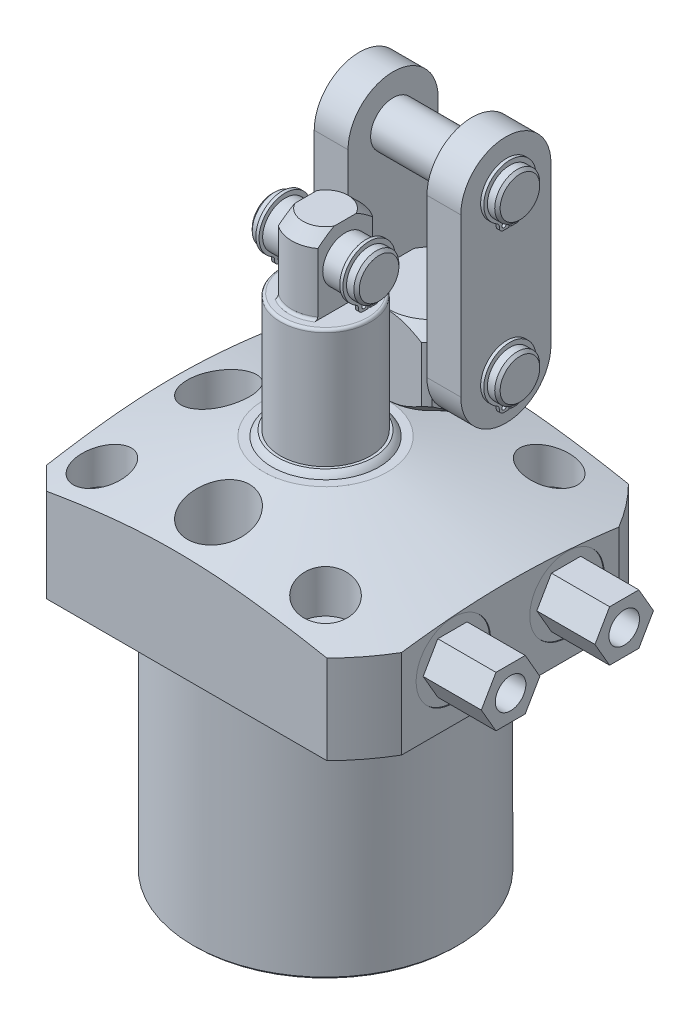
from build123d import *

# Parameters (mm, degrees)
SKETCH3_OUTSIDE_W          = 162.862
SKETCH3_OUTSIDE_H          = 162.862
SKETCH3_OUTSIDE_W_2        = 94.4626
SKETCH3_OUTSIDE_H_2        = 84.9376
CUT_EXTRUDE9_DEPTH         = 106.3498
CHAMFER8_SIZE              = 6.35
CHAMFER5_SIZE              = 0.762
HOLE1_D                    = 8.7376
HOLE1_DEPTH                = 36.4998
HOLE1_CBORE_D              = 14.2748
HOLE1_CBORE_DEPTH          = 17.4498
SKETCH34_R                 = 8.7503
CUT_EXTRUDE10_DEPTH        = 19.05
EXTRUDE14_DEPTH            = 16.383
HOLE2_D                    = 8.6106
HOLE2_DEPTH                = 6.7056
SKETCH33_R                 = 0.889
CUT_EXTRUDE7_DEPTH         = 20.6248
FILLET4_R                  = 0.762
SKETCH29_R                 = 6.3373
EXTRUDE11_DEPTH            = 15.0749
EXTRUDE2_START             = -2.8194
SKETCH16_R                 = 0.5969
EXTRUDE2_DEPTH             = 0.889
CHAMFER6_SIZE              = 0.762
CUT_EXTRUDE11_DEPTH        = 22.225
SKETCH30_R                 = 6.3373
EXTRUDE12_DEPTH            = 24.5999
EXTRUDE4_START             = -2.8194
SKETCH19_R                 = 0.5969
EXTRUDE4_DEPTH             = 0.889
EXTRUDE13_DEPTH            = 9.525
CHAMFER7_SIZE              = 0.762
LPATTERN2_COUNT            = 2
LPATTERN2_PITCH            = 44.45
LPATTERN2_START            = -2.8194
LPATTERN2_COPY_1_SKETCH_R  = 0.5969
LPATTERN2_COPY_1_DEPTH     = 0.889
CHAMFER7_OF_LPATTERN2_SIZE = 0.762


with BuildPart() as part:
    # Sketch28 → Revolve7 (revolve)
    with BuildSketch(Plane.XY, mode=Mode.PRIVATE) as revolve7_sk:
        Polygon((-17.4625, 36.4998), (-60.325, 25.014827739), (-60.325, 0), (-37.2999, 0), (-37.2999, -69.85), (0, -69.85), (0, 36.4998), align=None)
    revolve(revolve7_sk.sketch.rotate(Axis((0, 0, 0), (0, 1, 0)), 270), axis=Axis((0, 0, 0), (0, 1, 0)))  # turned: the seam where the file's is

    # Sketch3 outside → Cut-Extrude9 (cut)
    with BuildSketch(Plane(origin=(0, 36.4998, 0), x_dir=(-1, 0, 0), z_dir=(0, 1, 0))):
        Rectangle(SKETCH3_OUTSIDE_W, SKETCH3_OUTSIDE_H)
        with Locations((-4.7625, 0)):
            Rectangle(SKETCH3_OUTSIDE_W_2, SKETCH3_OUTSIDE_H_2, mode=Mode.SUBTRACT)
    extrude(amount=-CUT_EXTRUDE9_DEPTH, mode=Mode.SUBTRACT)

    # Chamfer8
    chamfer8_edges = [part.edges().sort_by_distance(p)[0] for p in [
        (-42.4688, 12.542923443, -42.4688),
        (-42.4688, 12.542923443, 42.4688),
    ]]
    chamfer(chamfer8_edges, length=CHAMFER8_SIZE)

    # Chamfer5
    chamfer5_edges = [part.edges().sort_by_distance(p)[0] for p in [
        (0, -69.85, 37.2999),
    ]]
    chamfer(chamfer5_edges, length=CHAMFER5_SIZE)

    # Hole1
    with Locations(Plane(origin=(0, 36.4998, 0), x_dir=(-1, 0, 0), z_dir=(0, 1, 0))):
        with Locations((-31.496, -31.496), (-31.496, 31.496), (31.496, -31.496), (31.496, 31.496)):
            CounterBoreHole(HOLE1_D / 2, HOLE1_CBORE_D / 2, HOLE1_CBORE_DEPTH, depth=HOLE1_DEPTH)

    # Sketch34 → Cut-Extrude10 (cut)
    with BuildSketch(Plane(origin=(0, 36.4998, 0), x_dir=(1, 0, 0), z_dir=(0, 1, 0))):
        with Locations(Location((0, 30.1498, 0), (0, 0, 270))):  # turned: the seam where the file's is
            Circle(SKETCH34_R)
        with Locations(Location((0, -30.1498, 0), (0, 0, 136.329694208))):  # turned: the seam where the file's is
            Circle(SKETCH34_R)
        with Locations(Location((-30.1498, 0, 0), (0, 0, 270))):  # turned: the seam where the file's is
            Circle(SKETCH34_R)
    extrude(amount=-CUT_EXTRUDE10_DEPTH, mode=Mode.SUBTRACT)

    # S2D0007 → Cut-Revolve2 (revolve, cut)
    with BuildSketch(Plane.XZ.offset(-15.875)):
        Polygon((51.9938, -16.002), (51.9938, -26.4795), (51.7398, -26.4795), (51.7398, -22.21865), (49.6697, -21.778636662), (48.871463338, -20.9804), (37.7698, -20.9804), (34.778475494, -16.002), align=None)
    cut_revolve2 = revolve(axis=Axis((-11.746808274, 15.875, -16.002), (-1, 0, 0)), mode=Mode.SUBTRACT)

    # Sketch6 → Cut-Revolve3 (revolve, cut)
    with BuildSketch(Plane.XY.offset(-16.002), mode=Mode.PRIVATE) as cut_revolve3_sk:
        with BuildLine():
            Line((50.67935, 0), (50.67935, 1.4478))
            Line((50.67935, 1.4478), (47.61885581, 1.4478))
            ThreePointArc((47.61885581, 1.4478), (46.937254622, 0.917608896), (46.1518, 0.5588))
            Line((46.1518, 0.5588), (45.0088, 0.5588))
            Line((45.0088, 0.5588), (45.0088, 0))
            Line((45.0088, 0), (50.67935, 0))
        make_face()
    cut_revolve3 = revolve(cut_revolve3_sk.sketch.rotate(Axis((45.0088, -21.049171587, -16.002), (0, 1, 0)), 90), axis=Axis((45.0088, -21.049171587, -16.002), (0, 1, 0)), mode=Mode.SUBTRACT)  # turned: the seam where the file's is

    # Sketch38 → Extrude14 (add)
    with BuildSketch(Plane(origin=(51.7398, 0, 0), x_dir=(0, 0, -1), z_dir=(1, 0, 0))):
        Polygon((24.243559623, 15.875), (20.122779811, 23.0124), (11.881220189, 23.0124), (7.760440377, 15.875), (11.881220189, 8.7376), (20.122779811, 8.7376), align=None)
    extrude14 = extrude(amount=EXTRUDE14_DEPTH)

    # Hole2
    with Locations(Plane(origin=(68.1228, 0, 0), x_dir=(0, 0, -1), z_dir=(1, 0, 0))):
        with Locations((16.002, 15.875)):
            hole2 = Hole(HOLE2_D / 2, depth=HOLE2_DEPTH)

    # Mirror6: Cut-Revolve2, Cut-Revolve3, Extrude14, Hole2 across plane
    add(cut_revolve2.mirror(Plane.XY), mode=Mode.SUBTRACT)
    add(cut_revolve3.mirror(Plane.XY), mode=Mode.SUBTRACT)
    add(extrude14.mirror(Plane.XY))
    add(hole2.mirror(Plane.XY), mode=Mode.SUBTRACT)

    # Sketch12 → Revolve2 (revolve)
    with BuildSketch(Plane(origin=(0, 0, 0), x_dir=(-1, 0, 0), z_dir=(0, 0, -1)), mode=Mode.PRIVATE) as revolve2_sk:
        with BuildLine():
            Line((0, 36.4998), (0, 38.0238))
            Line((0, 38.0238), (13.462, 38.0238))
            ThreePointArc((13.462, 38.0238), (14.358696206, 37.357310568), (15.0749, 36.4998))
            Line((15.0749, 36.4998), (0, 36.4998))
        make_face()
    revolve(revolve2_sk.sketch.rotate(Axis((0, 22.10562, 0), (0, 1, 0)), 270), axis=Axis((0, 22.10562, 0), (0, 1, 0)))  # turned: the seam where the file's is

    # Sketch13 → Revolve3 (revolve)
    with BuildSketch(Plane.XY, mode=Mode.PRIVATE) as revolve3_sk:
        Polygon((0, 38.0238), (0, 92.075), (6.35, 92.075), (9.525, 88.9), (9.525, 71.4502), (12.69365, 71.4502), (12.69365, 38.0238), align=None)
    revolve(revolve3_sk.sketch.rotate(Axis((0, 23.02637, 0), (0, 1, 0)), 90), axis=Axis((0, 23.02637, 0), (0, 1, 0)))  # turned: the seam where the file's is

    # Sketch14 → Cut-Extrude7 (cut)
    with BuildSketch(Plane(origin=(0, 92.075, 0), x_dir=(-1, 0, 0), z_dir=(0, 1, 0))):
        with BuildLine():
            Line((5.5499, 7.741074537), (5.5499, -7.741074537))
            ThreePointArc((5.5499, -7.741074537), (9.525, 0), (5.5499, 7.741074537))
        make_face()
        with BuildLine():
            Line((-5.5499, -7.741074537), (-5.5499, 7.741074537))
            ThreePointArc((-5.5499, 7.741074537), (-9.525, 0), (-5.5499, -7.741074537))
        make_face()
    extrude(amount=-CUT_EXTRUDE7_DEPTH, mode=Mode.SUBTRACT)

    # Fillet4
    fillet4_edges = [part.edges().sort_by_distance(p)[0] for p in [
        (0, 71.4502, 12.69365),
        (0, 71.4502, -9.525),
        (0, 71.4502, 9.525),
    ]]
    fillet(fillet4_edges, radius=FILLET4_R)

    # Sketch29 → Extrude11 (add, symmetric)
    with BuildSketch(Plane.ZY):
        with Locations((0, 82.55)):
            Circle(SKETCH29_R)
    extrude(amount=EXTRUDE11_DEPTH, both=True)

    # Sketch16 → Extrude2 (add)
    with BuildSketch(Plane(origin=(-15.0749, 52.3748, 0), x_dir=(0, 0, 1), z_dir=(-1, 0, 0)).offset(EXTRUDE2_START)):
        with BuildLine():
            Line((0.23876, 24.236397543), (0.23876, 21.493197543))
            Line((0.23876, 21.493197543), (1.78816, 21.493197543))
            ThreePointArc((1.78816, 21.493197543), (2.632304075, 21.842853468), (2.98196, 22.686997543))
            Line((2.98196, 22.686997543), (2.98196, 22.931638033))
            ThreePointArc((2.98196, 22.931638033), (3.14610012, 23.535756375), (3.593383976, 23.973749643))
            ThreePointArc((3.593383976, 23.973749643), (0, 37.7698), (-3.593383976, 23.973749643))
            ThreePointArc((-3.593383976, 23.973749643), (-3.14610012, 23.535756375), (-2.98196, 22.931638033))
            Line((-2.98196, 22.931638033), (-2.98196, 22.686997543))
            ThreePointArc((-2.98196, 22.686997543), (-2.632304075, 21.842853468), (-1.78816, 21.493197543))
            Line((-1.78816, 21.493197543), (-0.23876, 21.493197543))
            Line((-0.23876, 21.493197543), (-0.23876, 24.236397543))
            ThreePointArc((-0.23876, 24.236397543), (0, 36.1188), (0.23876, 24.236397543))
        make_face()
        with Locations((1.43256, 22.686997543)):
            Circle(SKETCH16_R, mode=Mode.SUBTRACT)
        with Locations(Location((-1.43256, 22.686997543, 0), (0, 0, 180))):  # turned: the seam where the file's is
            Circle(SKETCH16_R, mode=Mode.SUBTRACT)
    extrude2 = extrude(amount=-EXTRUDE2_DEPTH)

    # Chamfer6
    chamfer6_edges = [part.edges().sort_by_distance(p)[0] for p in [
        (15.0749, 82.55, -6.3373),
        (-15.0749, 82.55, -6.3373),
    ]]
    chamfer(chamfer6_edges, length=CHAMFER6_SIZE)

    # Mirror2: Extrude2 across plane
    add(extrude2.mirror(Plane.ZY))

    # Sketch35 → Revolve10 (revolve)
    with BuildSketch(Plane.ZY):
        Polygon((-30.1498, 17.4498), (-20.6248, 17.4498), (-20.6248, 36.4998), (-17.5768, 36.4998), (-14.2748, 39.8018), (-14.2748, 55.4228), (-17.5768, 58.7248), (-30.1498, 58.7248), align=None)
    revolve(axis=Axis((0, 43.57409058, -30.1498), (0, -1, 0)))

    # Sketch36 → Cut-Extrude11 (cut)
    with BuildSketch(Plane(origin=(0, 58.7248, 0), x_dir=(1, 0, 0), z_dir=(0, 1, 0))):
        with BuildLine():
            Line((11.1125, 41.48681763), (11.1125, 18.81278237))
            ThreePointArc((11.1125, 18.81278237), (15.875, 30.1498), (11.1125, 41.48681763))
        make_face()
        with BuildLine():
            Line((9.525, 42.8498), (-9.525, 42.8498))
            ThreePointArc((-9.525, 42.8498), (0, 46.0248), (9.525, 42.8498))
        make_face()
        with BuildLine():
            Line((-11.1125, 41.48681763), (-11.1125, 18.81278237))
            ThreePointArc((-11.1125, 18.81278237), (-15.875, 30.1498), (-11.1125, 41.48681763))
        make_face()
        with BuildLine():
            Line((9.525, 17.4498), (-9.525, 17.4498))
            ThreePointArc((-9.525, 17.4498), (0, 14.2748), (9.525, 17.4498))
        make_face()
    extrude(amount=-CUT_EXTRUDE11_DEPTH, mode=Mode.SUBTRACT)

    # Sketch30 → Extrude12 (add, symmetric)
    with BuildSketch(Plane.ZY):
        with Locations((-30.1498, 47.625)):
            Circle(SKETCH30_R)
    extrude12 = extrude(amount=EXTRUDE12_DEPTH, both=True)

    # Sketch19 → Extrude4 (add)
    with BuildSketch(Plane(origin=(-24.5999, 11.0998, -22.225), x_dir=(0, 0, 1), z_dir=(-1, 0, 0)).offset(EXTRUDE4_START)):
        with BuildLine():
            Line((-7.68604, 30.586397543), (-7.68604, 27.843197543))
            Line((-7.68604, 27.843197543), (-6.13664, 27.843197543))
            ThreePointArc((-6.13664, 27.843197543), (-5.292495925, 28.192853468), (-4.94284, 29.036997543))
            Line((-4.94284, 29.036997543), (-4.94284, 29.281638033))
            ThreePointArc((-4.94284, 29.281638033), (-4.77869988, 29.885756375), (-4.331416024, 30.323749643))
            ThreePointArc((-4.331416024, 30.323749643), (-7.9248, 44.1198), (-11.518183976, 30.323749643))
            ThreePointArc((-11.518183976, 30.323749643), (-11.07090012, 29.885756375), (-10.90676, 29.281638033))
            Line((-10.90676, 29.281638033), (-10.90676, 29.036997543))
            ThreePointArc((-10.90676, 29.036997543), (-10.557104075, 28.192853468), (-9.71296, 27.843197543))
            Line((-9.71296, 27.843197543), (-8.16356, 27.843197543))
            Line((-8.16356, 27.843197543), (-8.16356, 30.586397543))
            ThreePointArc((-8.16356, 30.586397543), (-7.9248, 42.4688), (-7.68604, 30.586397543))
        make_face()
        with Locations((-6.25348, 29.036997543)):
            Circle(SKETCH19_R, mode=Mode.SUBTRACT)
        with Locations(Location((-9.59612, 29.036997543, 0), (0, 0, 180))):  # turned: the seam where the file's is
            Circle(SKETCH19_R, mode=Mode.SUBTRACT)
    extrude4 = extrude(amount=-EXTRUDE4_DEPTH)

    # Sketch37 → Extrude13 (add)
    with BuildSketch(Plane.ZY.offset(11.1125)):
        with BuildLine():
            Line((-42.849800117, 92.074999966), (-42.8498, 47.624999966))
            ThreePointArc((-42.8498, 47.624999966), (-30.149799966, 34.925), (-17.4498, 47.625000034))
            Line((-17.4498, 47.625000034), (-17.449800117, 92.075000034))
            ThreePointArc((-17.449800117, 92.075000034), (-30.149800151, 104.775), (-42.849800117, 92.074999966))
        make_face()
    extrude13 = extrude(amount=EXTRUDE13_DEPTH)

    # Mirror3: Extrude4 across plane
    add(extrude4.mirror(Plane.ZY))

    # Chamfer7
    chamfer7_edges = [part.edges().sort_by_distance(p)[0] for p in [
        (24.5999, 47.625, -36.4871),
        (-24.5999, 47.625, -36.4871),
    ]]
    chamfer(chamfer7_edges, length=CHAMFER7_SIZE)

    # LPattern2: Extrude4, Extrude12 ×2
    with Locations(*[(0, i * LPATTERN2_PITCH, 0) for i in range(1, LPATTERN2_COUNT)]):
        add(extrude4)
        add(extrude12)

    # LPattern2 copy 1 sketch → LPattern2 copy 1 (add)
    with BuildSketch(Plane(origin=(24.5999, 55.5498, -22.225000117), x_dir=(0, 0, 1), z_dir=(1, 0, 0)).offset(LPATTERN2_START)):
        with BuildLine():
            Line((-7.68604, -30.586397543), (-7.68604, -27.843197543))
            Line((-7.68604, -27.843197543), (-6.13664, -27.843197543))
            ThreePointArc((-6.13664, -27.843197543), (-5.292495925, -28.192853468), (-4.94284, -29.036997543))
            Line((-4.94284, -29.036997543), (-4.94284, -29.281638033))
            ThreePointArc((-4.94284, -29.281638033), (-4.77869988, -29.885756375), (-4.331416024, -30.323749643))
            ThreePointArc((-4.331416024, -30.323749643), (-7.9248, -44.1198), (-11.518183976, -30.323749643))
            ThreePointArc((-11.518183976, -30.323749643), (-11.07090012, -29.885756375), (-10.90676, -29.281638033))
            Line((-10.90676, -29.281638033), (-10.90676, -29.036997543))
            ThreePointArc((-10.90676, -29.036997543), (-10.557104075, -28.192853468), (-9.71296, -27.843197543))
            Line((-9.71296, -27.843197543), (-8.16356, -27.843197543))
            Line((-8.16356, -27.843197543), (-8.16356, -30.586397543))
            ThreePointArc((-8.16356, -30.586397543), (-7.9248, -42.4688), (-7.68604, -30.586397543))
        make_face()
        with Locations((-6.25348, -29.036997543)):
            Circle(LPATTERN2_COPY_1_SKETCH_R, mode=Mode.SUBTRACT)
        with Locations((-9.59612, -29.036997543)):
            Circle(LPATTERN2_COPY_1_SKETCH_R, mode=Mode.SUBTRACT)
    extrude(amount=-LPATTERN2_COPY_1_DEPTH)

    # Chamfer7 of LPattern2
    chamfer7_of_lpattern2_edges = [part.edges().sort_by_distance(p)[0] for p in [
        (24.5999, 92.075, -36.487100117),
        (-24.5999, 92.075, -36.487100117),
    ]]
    chamfer(chamfer7_of_lpattern2_edges, length=CHAMFER7_OF_LPATTERN2_SIZE)

    # Mirror8: Extrude13 across plane
    add(extrude13.mirror(Plane.ZY))


with BuildPart() as body_2:
    # Sketch33 → Revolve9 (revolve)
    with BuildSketch(Plane.XY.offset(-16.002), mode=Mode.PRIVATE) as revolve9_sk:
        with Locations((40.22725, 0.5842)):
            Circle(SKETCH33_R)
    revolve(revolve9_sk.sketch.rotate(Axis((45.0088, 8.329668034, -16.002), (0, -1, 0)), 90), axis=Axis((45.0088, 8.329668034, -16.002), (0, -1, 0)))  # turned: the seam where the file's is


with BuildPart() as body_3:
    # Mirror7: mirrored copy
    add(body_2.part.mirror(Plane.XY))


solid = Compound([part.part, body_2.part, body_3.part])
